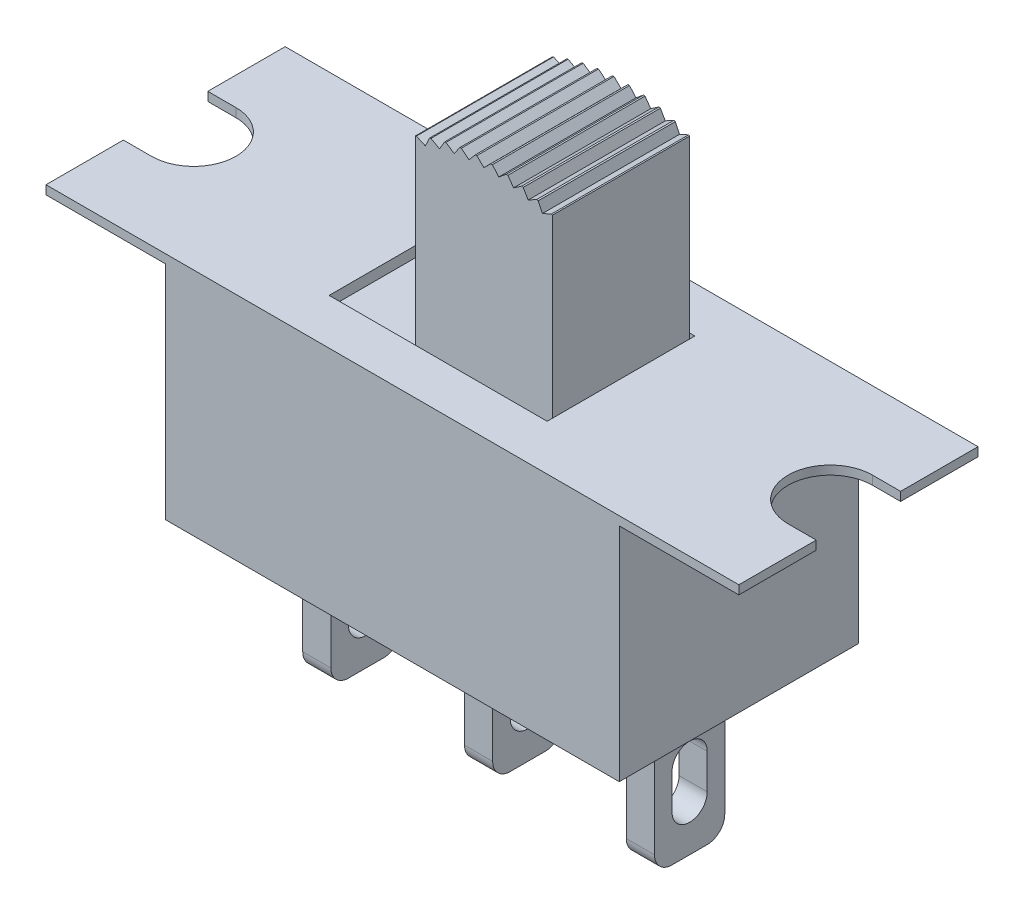
from build123d import *

# Parameters (mm, degrees)
BOSS_EXTRU_1_DEPTH      = 3.4
BOSS_EXTRU_1_DEPTH_BACK = 3.4
ENL_V_MAT_EXTRU_1_DEPTH = 6.8
ESQUISSE4_W             = 6.2
ESQUISSE4_H             = 4.2
ENL_V_MAT_EXTRU_2_DEPTH = 0.3
BOSS_EXTRU_2_DEPTH      = 1.95
BOSS_EXTRU_2_DEPTH_BACK = 1.95
ESQUISSE7_W             = 0.8
ESQUISSE7_H             = 2
BOSS_EXTRU_3_DEPTH      = 4.2
CONG_1_R                = 0.5
ENL_V_MAT_EXTRU_3_DEPTH = 10.2


with BuildPart() as part:
    # Esquisse1 → Boss.-Extru.1 (new, two sides: drawn at the far end of the back side and taken through both)
    with BuildSketch(Plane.XY.offset(-BOSS_EXTRU_1_DEPTH_BACK)):
        Polygon((-6.45, 3.275), (6.45, 3.275), (9.85, 3.275), (9.85, 3.025), (6.45, 3.025), (6.45, -3.275), (-6.45, -3.275), (-6.45, 3.025), (-9.85, 3.025), (-9.85, 3.275), align=None)
    extrude(amount=BOSS_EXTRU_1_DEPTH + BOSS_EXTRU_1_DEPTH_BACK)

    # Esquisse3 → Enlèv. mat.-Extru.1 (cut)
    with BuildSketch(Plane(origin=(0, 3.275, 0), x_dir=(1, 0, 0), z_dir=(0, 1, 0))):
        with BuildLine():
            Line((-9.05, 1.2), (-9.85, 1.2))
            Line((-9.85, 1.2), (-9.85, -1.2))
            Line((-9.85, -1.2), (-9.05, -1.2))
            ThreePointArc((-9.05, -1.2), (-7.85, 0), (-9.05, 1.2))
        make_face()
        with BuildLine():
            Line((9.05, -1.2), (9.85, -1.2))
            Line((9.85, -1.2), (9.85, 1.2))
            Line((9.85, 1.2), (9.05, 1.2))
            ThreePointArc((9.05, 1.2), (7.85, 0), (9.05, -1.2))
        make_face()
    extrude(amount=-ENL_V_MAT_EXTRU_1_DEPTH, mode=Mode.SUBTRACT)

    # Esquisse4 → Enlèv. mat.-Extru.2 (cut)
    with BuildSketch(Plane(origin=(0, 3.275, 0), x_dir=(1, 0, 0), z_dir=(0, 1, 0))):
        Rectangle(ESQUISSE4_W, ESQUISSE4_H)
    extrude(amount=-ENL_V_MAT_EXTRU_2_DEPTH, mode=Mode.SUBTRACT)

    # Esquisse6 → Boss.-Extru.2 (add, two sides: drawn at the far end of the back side and taken through both)
    with BuildSketch(Plane.XY.offset(-BOSS_EXTRU_2_DEPTH_BACK)):
        with BuildLine():
            Line((-0.8, 2.975), (3.1, 2.975))
            Line((3.1, 2.975), (3.1, 8.275))
            ThreePointArc((3.1, 8.275), (3.084706872, 8.281447306), (3.069392428, 8.287843813))
            Line((3.069392428, 8.287843813), (2.813852393, 8.173324546))
            Line((2.813852393, 8.173324546), (2.694192526, 8.426498179))
            ThreePointArc((2.694192526, 8.426498179), (2.674028844, 8.432998384), (2.6538378, 8.439413095))
            Line((2.6538378, 8.439413095), (2.409418963, 8.302757307))
            Line((2.409418963, 8.302757307), (2.267851834, 8.544364675))
            ThreePointArc((2.267851834, 8.544364675), (2.247192567, 8.549057375), (2.226513602, 8.553662498))
            Line((2.226513602, 8.553662498), (1.995128872, 8.395939706))
            Line((1.995128872, 8.395939706), (1.832762436, 8.624089904))
            ThreePointArc((1.832762436, 8.624089904), (1.811769271, 8.626938372), (1.790764225, 8.629697865))
            Line((1.790764225, 8.629697865), (1.574224502, 8.452142463))
            Line((1.574224502, 8.452142463), (1.392329497, 8.665049906))
            ThreePointArc((1.392329497, 8.665049906), (1.371166734, 8.66603185), (1.35, 8.666924116))
            Line((1.35, 8.666924116), (1.15, 8.470925717))
            Line((1.15, 8.470925717), (0.95, 8.666924116))
            ThreePointArc((0.95, 8.666924116), (0.928833266, 8.66603185), (0.907670503, 8.665049906))
            Line((0.907670503, 8.665049906), (0.725775498, 8.452142463))
            Line((0.725775498, 8.452142463), (0.509235775, 8.629697865))
            ThreePointArc((0.509235775, 8.629697865), (0.488230729, 8.626938372), (0.467237564, 8.624089904))
            Line((0.467237564, 8.624089904), (0.304871128, 8.395939706))
            Line((0.304871128, 8.395939706), (0.073486398, 8.553662498))
            ThreePointArc((0.073486398, 8.553662498), (0.052807433, 8.549057375), (0.032148166, 8.544364675))
            Line((0.032148166, 8.544364675), (-0.109418963, 8.302757307))
            Line((-0.109418963, 8.302757307), (-0.3538378, 8.439413095))
            ThreePointArc((-0.3538378, 8.439413095), (-0.374028844, 8.432998384), (-0.394192526, 8.426498179))
            Line((-0.394192526, 8.426498179), (-0.513852393, 8.173324546))
            Line((-0.513852393, 8.173324546), (-0.769392428, 8.287843813))
            ThreePointArc((-0.769392428, 8.287843813), (-0.784706872, 8.281447306), (-0.8, 8.275))
            Line((-0.8, 8.275), (-0.8, 2.975))
        make_face()
    extrude(amount=BOSS_EXTRU_2_DEPTH + BOSS_EXTRU_2_DEPTH_BACK)

    # Esquisse7 → Boss.-Extru.3 (add)
    with BuildSketch(Plane.XZ.offset(3.275)):
        with Locations((-4.55, 0)):
            Rectangle(ESQUISSE7_W, ESQUISSE7_H)
        with Locations((0.05, 0)):
            Rectangle(ESQUISSE7_W, ESQUISSE7_H)
        with Locations((4.65, 0)):
            Rectangle(ESQUISSE7_W, ESQUISSE7_H)
    extrude(amount=BOSS_EXTRU_3_DEPTH)

    # Congé1
    cong_1_edges = [part.edges().sort_by_distance(p)[0] for p in [
        (-4.55, -7.475, -1),
        (0.05, -7.475, -1),
        (4.65, -7.475, -1),
        (0.05, -7.475, 1),
        (4.65, -7.475, 1),
        (-4.55, -7.475, 1),
    ]]
    fillet(cong_1_edges, radius=CONG_1_R)

    # Esquisse8 → Enlèv. mat.-Extru.3 (cut)
    with BuildSketch(Plane(origin=(5.05, 0, 0), x_dir=(0, 0, -1), z_dir=(1, 0, 0))):
        with BuildLine():
            Line((0.5, -5.175), (0.5, -6.175))
            ThreePointArc((0.5, -6.175), (0, -6.675), (-0.5, -6.175))
            Line((-0.5, -6.175), (-0.5, -5.175))
            ThreePointArc((-0.5, -5.175), (0, -4.675), (0.5, -5.175))
        make_face()
    extrude(amount=-ENL_V_MAT_EXTRU_3_DEPTH, mode=Mode.SUBTRACT)


solid = part.part
